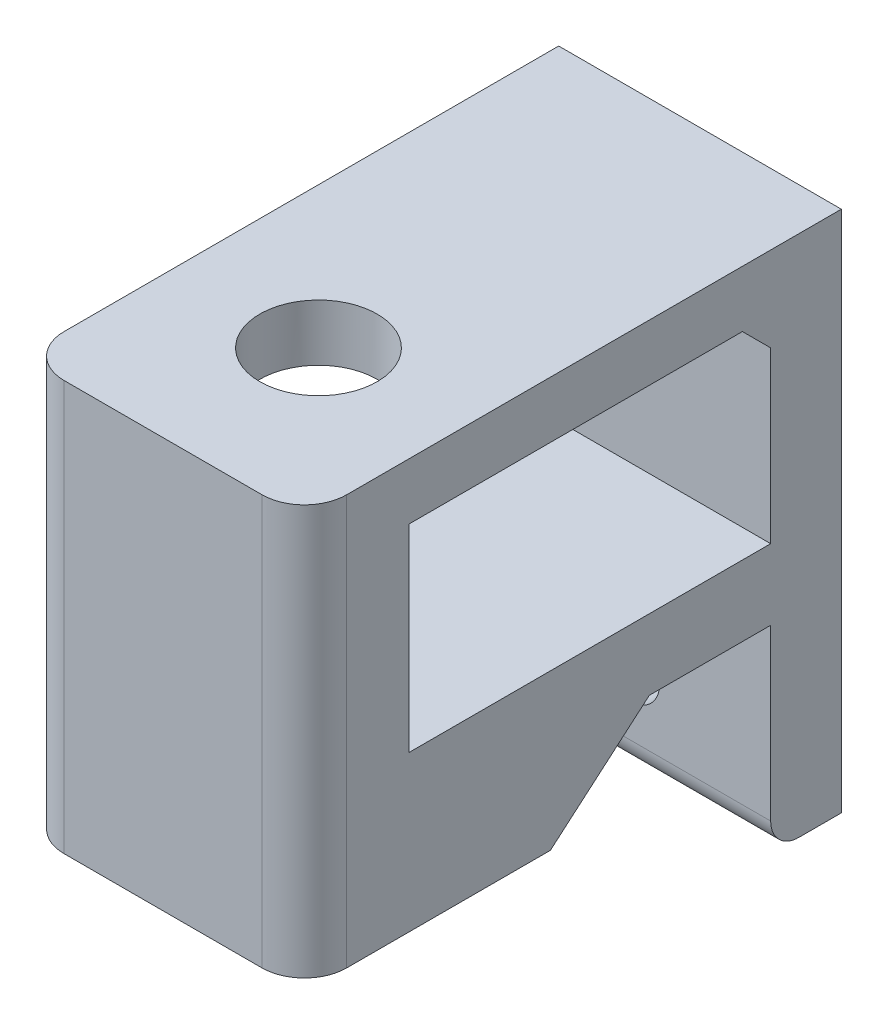
from build123d import *

# Parameters (mm, degrees)
SKETCH1_W           = 20
SKETCH1_H           = 33
SKETCH1_R           = 2.15
BOSS_EXTRUDE1_DEPTH = 5
SKETCH2_W           = 20
SKETCH2_H           = 4
BOSS_EXTRUDE2_DEPTH = 38
SKETCH4_W           = 20
SKETCH4_H           = 7.411842069
BOSS_EXTRUDE3_DEPTH = 25
FILLET1_R           = 3
FILLET2_R           = 2
CHAMFER2_SIZE       = 2
SKETCH8_W           = 20
SKETCH8_H           = 5
BOSS_EXTRUDE5_DEPTH = 25.588158
SKETCH12_W          = 20
SKETCH12_H          = 10
BOSS_EXTRUDE6_DEPTH = 14
SKETCH3_R           = 4.15
CUT_EXTRUDE2_DEPTH  = 18
SKETCH15_W          = 20
SKETCH15_H          = 6
BOSS_EXTRUDE7_DEPTH = 10
SKETCH16_W          = 20
SKETCH16_H          = 14
CUT_EXTRUDE4_DEPTH  = 10
BOSS_EXTRUDE8_DEPTH = 20


with BuildPart() as part:
    # Sketch1 → Boss-Extrude1 (new body)
    with BuildSketch(Plane.XY):
        with Locations((10, -16.5)):
            Rectangle(SKETCH1_W, SKETCH1_H)
        with Locations((10, -6.5)):
            Circle(SKETCH1_R, mode=Mode.SUBTRACT)
        with Locations((10, -26.5)):
            Circle(SKETCH1_R, mode=Mode.SUBTRACT)
    extrude(amount=BOSS_EXTRUDE1_DEPTH)

    # Sketch2 → Boss-Extrude2 (add)
    with BuildSketch(Plane(origin=(0, 0, 0), x_dir=(-1, 0, 0), z_dir=(0, 0, -1))):
        with Locations((-10, 2)):
            Rectangle(SKETCH2_W, SKETCH2_H)
    extrude(amount=-BOSS_EXTRUDE2_DEPTH)

    # Sketch4 → Boss-Extrude3 (add)
    with BuildSketch(Plane.XZ):
        with Locations((10, 34.294078965)):
            Rectangle(SKETCH4_W, SKETCH4_H)
    extrude(amount=BOSS_EXTRUDE3_DEPTH)

    # Fillet1
    fillet1_edges = [part.edges().sort_by_distance(p)[0] for p in [
        (20, -10.5, 38),
        (0, -10.5, 38),
    ]]
    fillet(fillet1_edges, radius=FILLET1_R)

    # Fillet2
    fillet2_edges = [part.edges().sort_by_distance(p)[0] for p in [
        (10, -33, 5),
    ]]
    fillet(fillet2_edges, radius=FILLET2_R)

    # Chamfer2
    chamfer2_edges = [part.edges().sort_by_distance(p)[0] for p in [
        (10, 0, 5),
    ]]
    chamfer(chamfer2_edges, length=CHAMFER2_SIZE)

    # Sketch8 → Boss-Extrude5 (add)
    with BuildSketch(Plane.XY.offset(5)):
        with Locations((10, -16.5)):
            Rectangle(SKETCH8_W, SKETCH8_H)
    extrude(amount=BOSS_EXTRUDE5_DEPTH)

    # Sketch12 → Boss-Extrude6 (add)
    with BuildSketch(Plane(origin=(0, -14, 0), x_dir=(1, 0, 0), z_dir=(0, 1, 0))):
        with Locations((10, -25.588157931)):
            Rectangle(SKETCH12_W, SKETCH12_H)
    extrude(amount=BOSS_EXTRUDE6_DEPTH)

    # Sketch3 → Cut-Extrude2 (cut)
    with BuildSketch(Plane(origin=(0, 4, 0), x_dir=(1, 0, 0), z_dir=(0, 1, 0))):
        with Locations((10, -27)):
            Circle(SKETCH3_R)
    extrude(amount=-CUT_EXTRUDE2_DEPTH, mode=Mode.SUBTRACT)

    # Sketch15 → Boss-Extrude7 (add)
    with BuildSketch(Plane(origin=(0, 0, 30.588157931), x_dir=(-1, 0, 0), z_dir=(0, 0, -1))):
        with Locations((-10, -22)):
            Rectangle(SKETCH15_W, SKETCH15_H)
    extrude(amount=BOSS_EXTRUDE7_DEPTH)

    # Sketch16 → Cut-Extrude4 (cut)
    with BuildSketch(Plane(origin=(0, 0, 20.588157931), x_dir=(-1, 0, 0), z_dir=(0, 0, -1))):
        with Locations((-10, -7)):
            Rectangle(SKETCH16_W, SKETCH16_H)
    extrude(amount=-CUT_EXTRUDE4_DEPTH, mode=Mode.SUBTRACT)

    # Sketch17 → Boss-Extrude8 (add)
    with BuildSketch(Plane(origin=(20, 0, 0), x_dir=(0, 0, -1), z_dir=(1, 0, 0))):
        Polygon((-20.588157931, -19), (-20.588157931, -25), (-13.588157931, -19), align=None)
    extrude(amount=-BOSS_EXTRUDE8_DEPTH)


solid = part.part
